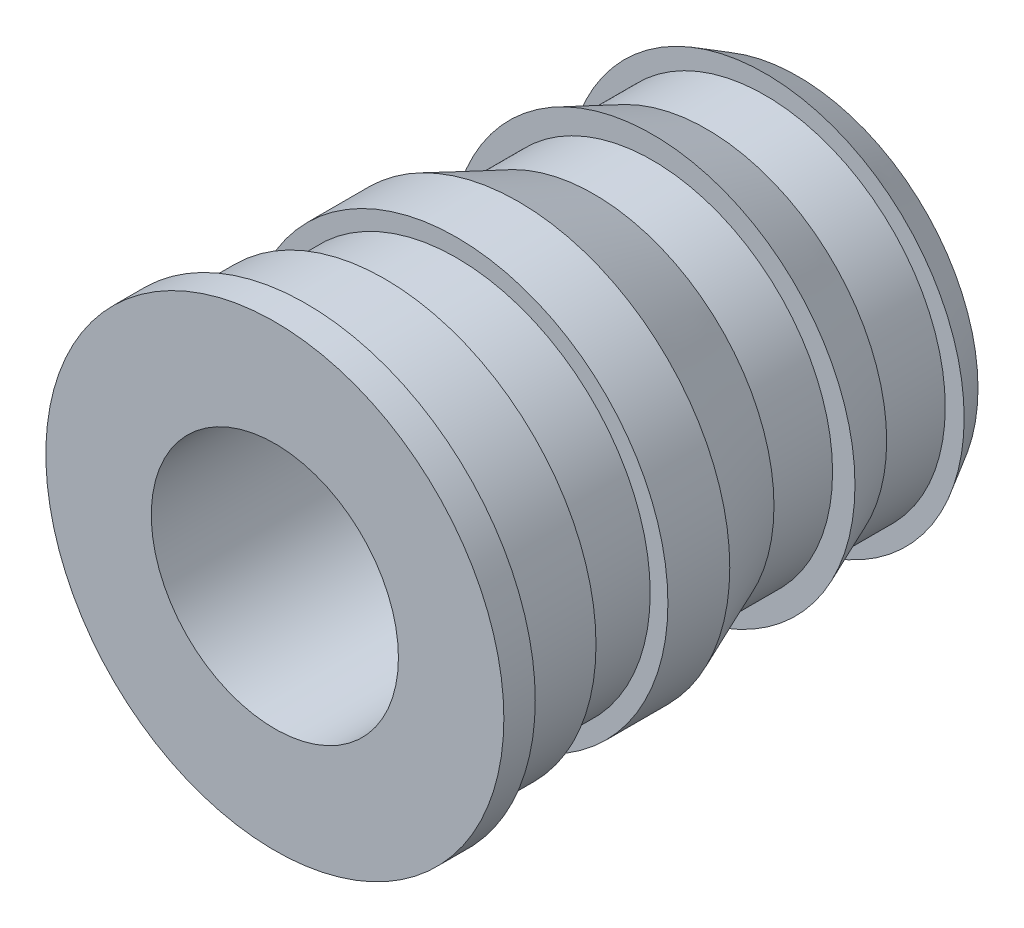
from build123d import *


with BuildPart() as part:
    # Sketch3 → Revolve1 (revolve)
    with BuildSketch(Plane(origin=(0, 0, 0), x_dir=(0, 0, -1), z_dir=(1, 0, 0))):
        Polygon((-3.175, 1.5), (-3.175, 2.78), (-2.794, 2.78), (-2.794, 2.565), (-1.8415, 2.565), (-1.8415, 2.35), (-0.968638131, 2.35), (-0.968638131, 2.565), (-0.217694047, 2.565), (0.6985, 2.1855), (1.409664125, 2.1855), (1.409664125, 2.4575), (2.066330214, 2.1855), (2.77749434, 2.1855), (2.77749434, 2.415), (3.175, 2.1855), (3.175, 1.5), align=None)
    revolve(axis=Axis((0, 0, 3.175), (0, 0, -1)))


solid = part.part
